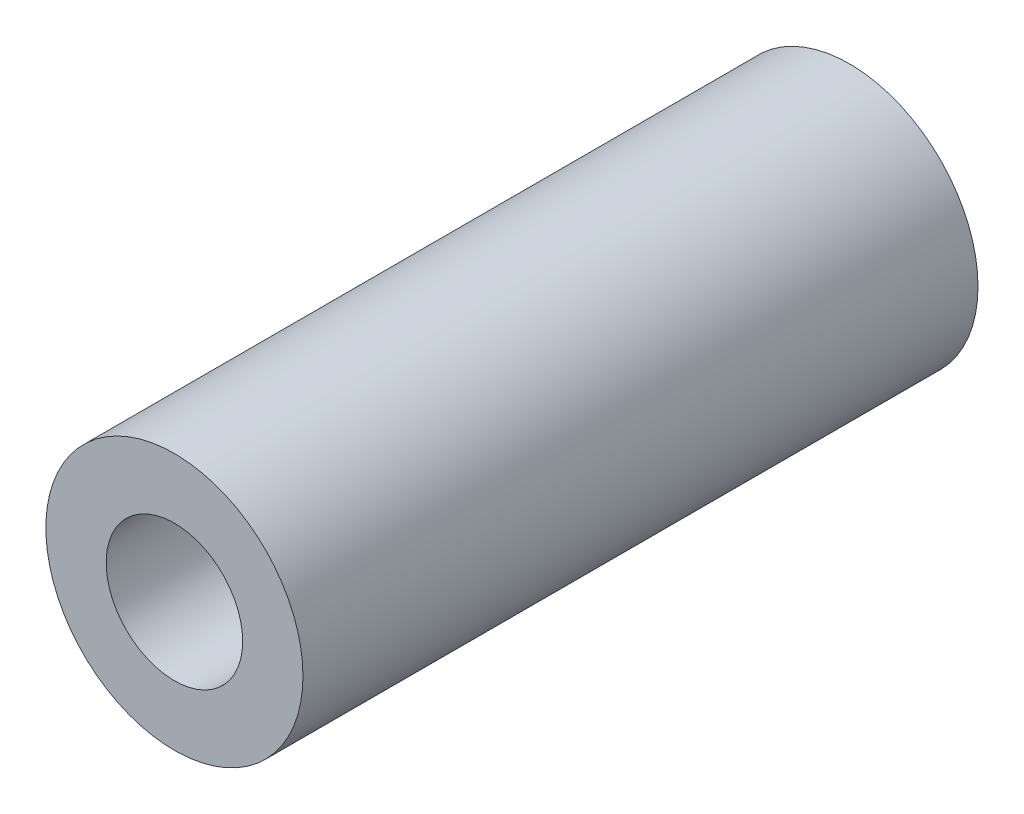
from build123d import *

# Parameters (mm, degrees)
ESQUISSE1_R        = 16.95
ESQUISSE1_R_2      = 9
BOSS_EXTRU_1_DEPTH = 89


with BuildPart() as part:
    # Esquisse1 → Boss.-Extru.1 (new body)
    with BuildSketch(Plane.XY):
        Circle(ESQUISSE1_R)
        Circle(ESQUISSE1_R_2, mode=Mode.SUBTRACT)
    extrude(amount=BOSS_EXTRU_1_DEPTH)


solid = part.part
